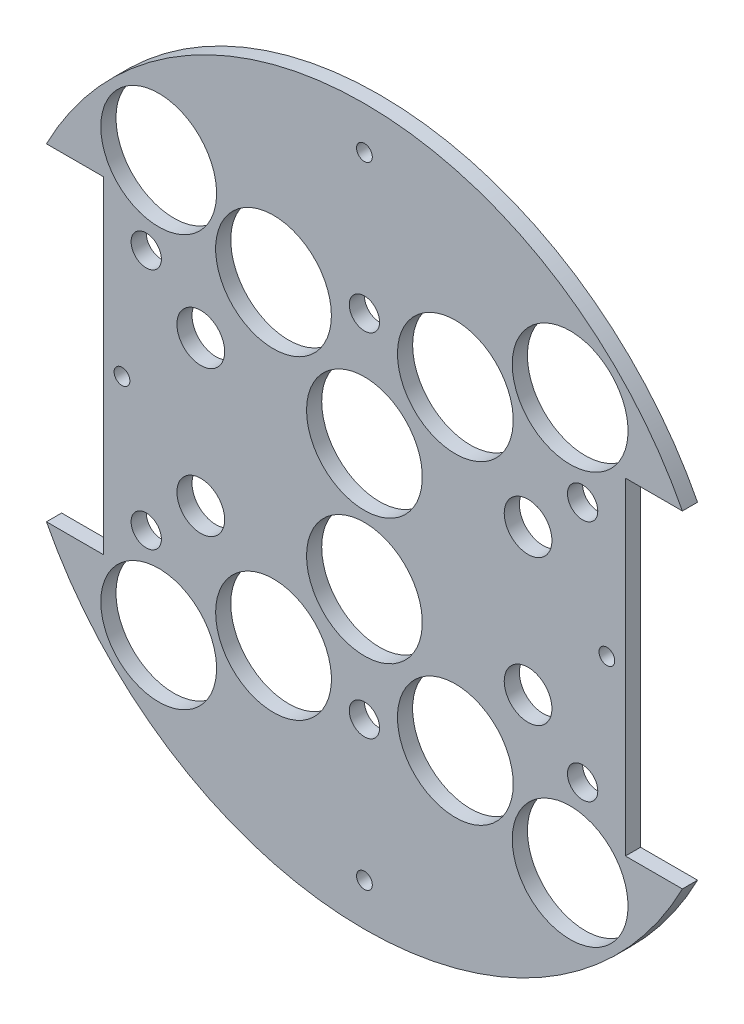
from build123d import *

# Parameters (mm, degrees)
SKETCH1_R               = 1.651
BOSS_EXTRUDE2_DEPTH     = 3.175
SKETCH3_R               = 12.1285
CUT_EXTRUDE2_DEPTH      = 4.175
SKETCH4_W               = 37.082318314
SKETCH4_H               = 34.047903563
SKETCH4_W_2             = 37.024578492
SKETCH4_H_2             = 32.488734362
BOSS_EXTRUDE3_DEPTH     = 3.175
SKETCH5_R               = 5
CUT_EXTRUDE3_DEPTH      = 4.175
SKETCH6_R               = 3.175
CUT_EXTRUDE4_DEPTH      = 1
CUT_EXTRUDE4_DEPTH_BACK = 4.175
SKETCH7_R               = 1.651
CUT_EXTRUDE5_DEPTH      = 16.51


with BuildPart() as part:
    # Sketch1 → Boss-Extrude2 (new body)
    with BuildSketch(Plane.XY):
        with BuildLine():
            Line((-66.623575407, 34.29), (-54.685575407, 34.29))
            Line((-54.685575407, 34.29), (-54.685575407, -34.29))
            Line((-54.685575407, -34.29), (-66.623575407, -34.29))
            ThreePointArc((-66.623575407, -34.29), (0, -74.93), (66.623575407, -34.29))
            Line((66.623575407, -34.29), (54.685575407, -34.29))
            Line((54.685575407, -34.29), (54.685575407, 34.29))
            Line((54.685575407, 34.29), (66.623575407, 34.29))
            ThreePointArc((66.623575407, 34.29), (0, 74.93), (-66.623575407, 34.29))
        make_face()
        with Locations((-45.466, 11.049)):
            Circle(SKETCH1_R, mode=Mode.SUBTRACT)
        with Locations((-20.067270032, 10.795)):
            Circle(SKETCH1_R, mode=Mode.SUBTRACT)
        with Locations((-20.067270032, -10.795)):
            Circle(SKETCH1_R, mode=Mode.SUBTRACT)
        with Locations((-45.466, -11.049)):
            Circle(SKETCH1_R, mode=Mode.SUBTRACT)
        with Locations((45.466, -11.049)):
            Circle(SKETCH1_R, mode=Mode.SUBTRACT)
        with Locations((20.067270032, -10.795)):
            Circle(SKETCH1_R, mode=Mode.SUBTRACT)
        with Locations((20.067270032, 10.795)):
            Circle(SKETCH1_R, mode=Mode.SUBTRACT)
        with Locations((45.466, 11.049)):
            Circle(SKETCH1_R, mode=Mode.SUBTRACT)
    extrude(amount=BOSS_EXTRUDE2_DEPTH)

    # Sketch3 → Cut-Extrude2 (cut, through all)
    with BuildSketch(Plane(origin=(0, 0, 0), x_dir=(-1, 0, 0), z_dir=(0, 0, -1))):
        with Locations((0, -13.208)):
            Circle(SKETCH3_R)
        with Locations((0, 13.208)):
            Circle(SKETCH3_R)
        with Locations((-43.105229381, -43.105229381)):
            Circle(SKETCH3_R)
        with Locations((19.05, -32.995567884)):
            Circle(SKETCH3_R)
        with Locations((19.05, 32.995567884)):
            Circle(SKETCH3_R)
        with Locations((-43.105229381, 43.105229381)):
            Circle(SKETCH3_R)
        with Locations((43.105229381, 43.105229381)):
            Circle(SKETCH3_R)
        with Locations((-19.05, 32.995567884)):
            Circle(SKETCH3_R)
        with Locations((-19.05, -32.995567884)):
            Circle(SKETCH3_R)
        with Locations((43.105229381, -43.105229381)):
            Circle(SKETCH3_R)
    extrude(amount=-CUT_EXTRUDE2_DEPTH, mode=Mode.SUBTRACT)

    # Sketch4 → Boss-Extrude3 (add)
    with BuildSketch(Plane(origin=(0, 0, 0), x_dir=(-1, 0, 0), z_dir=(0, 0, -1))):
        with Locations((32.991199211, -1.421154886)):
            Rectangle(SKETCH4_W, SKETCH4_H)
        with Locations((-34.085074962, -0.641570285)):
            Rectangle(SKETCH4_W_2, SKETCH4_H_2)
    extrude(amount=-BOSS_EXTRUDE3_DEPTH)

    # Sketch5 → Cut-Extrude3 (cut, through all)
    with BuildSketch(Plane(origin=(0, 0, 0), x_dir=(-1, 0, 0), z_dir=(0, 0, -1))):
        with Locations((34.29, -15.24)):
            Circle(SKETCH5_R)
        with Locations((-34.29, -15.24)):
            Circle(SKETCH5_R)
        with Locations((34.29, 15.24)):
            Circle(SKETCH5_R)
        with Locations((-34.29, 15.24)):
            Circle(SKETCH5_R)
    extrude(amount=-CUT_EXTRUDE3_DEPTH, mode=Mode.SUBTRACT)

    # Sketch6 → Cut-Extrude4 (cut, two sides)
    with BuildSketch(Plane(origin=(31.313436391, -132.613959999, 3.175), x_dir=(0, -1, 0), z_dir=(0, 0, 1))) as cut_extrude4_sk:
        with Locations((-158.013959999, 14.406563609)):
            Circle(SKETCH6_R)
        with Locations((-169.443959999, -31.313436391)):
            Circle(SKETCH6_R)
        with Locations((-158.013959999, -77.033436391)):
            Circle(SKETCH6_R)
        with Locations((-107.213959999, -77.033436391)):
            Circle(SKETCH6_R)
        with Locations((-95.783959999, -31.313436391)):
            Circle(SKETCH6_R)
        with Locations((-107.213959999, 14.406563609)):
            Circle(SKETCH6_R)
    extrude(amount=CUT_EXTRUDE4_DEPTH, mode=Mode.SUBTRACT)
    extrude(cut_extrude4_sk.sketch, amount=-CUT_EXTRUDE4_DEPTH_BACK, mode=Mode.SUBTRACT)

    # Sketch7 → Cut-Extrude5 (cut)
    with BuildSketch(Plane(origin=(31.313436391, -132.613959999, 15.875), x_dir=(0, -1, 0), z_dir=(0, 0, 1))):
        with Locations((-198.653959999, -31.313436391)):
            Circle(SKETCH7_R)
        with Locations((-66.573959999, -31.313436391)):
            Circle(SKETCH7_R)
        with Locations((-132.613959999, -82.113436391)):
            Circle(SKETCH7_R)
        with Locations((-132.613959999, 19.486563609)):
            Circle(SKETCH7_R)
    extrude(amount=-CUT_EXTRUDE5_DEPTH, mode=Mode.SUBTRACT)


solid = part.part
